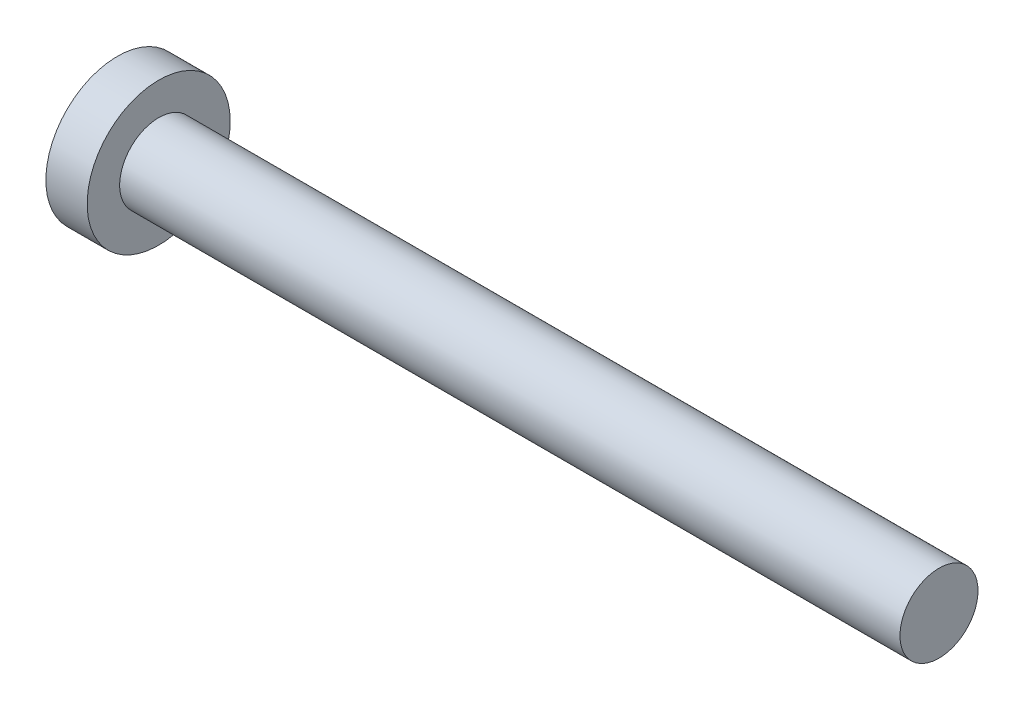
from build123d import *

# Parameters (mm, degrees)
CUT_EXTRUDE2_DEPTH = 1.43
FILLET5_R          = 0.3
DRAFT2_ANGLE       = -30


with BuildPart() as part:
    # Sketch1 → Base (revolve)
    with BuildSketch(Plane.XY):
        with BuildLine():
            Line((32.15, 1.5), (3.15, 1.5))
            Line((3.15, 1.5), (2.15, 1.5))
            Line((2.15, 1.5), (2.15, 1.8))
            Line((2.15, 1.8), (2.15, 2.75))
            Line((2.15, 2.75), (0.562803405, 2.75))
            ThreePointArc((0.562803405, 2.75), (0.142144061, 1.403499882), (0, 0))
            Line((0, 0), (32.15, 0))
            Line((32.15, 0), (32.15, 1.5))
        make_face()
    revolve(axis=Axis((4.515812911, 0, 0), (-1, 0, 0)))

    # Sketch6 → Cut-Extrude2 (cut)
    with BuildSketch(Plane(origin=(0, 0, 0), x_dir=(0, 0, -1), z_dir=(1, 0, 0))):
        Polygon((0.35, 0.35), (0.35, 1.75), (-0.35, 1.75), (-0.35, 0.35), (-1.75, 0.35), (-1.75, -0.35), (-0.35, -0.35), (-0.35, -1.75), (0.35, -1.75), (0.35, -0.35), (1.75, -0.35), (1.75, 0.35), align=None)
    extrude(amount=CUT_EXTRUDE2_DEPTH, mode=Mode.SUBTRACT)

    # Fillet5
    fillet5_edges = [part.edges().sort_by_distance(p)[0] for p in [
        (0.723760965, 0.35, 0.35),
        (0.723760965, -0.35, 0.35),
        (0.723760965, -0.35, -0.35),
        (0.723760965, 0.35, -0.35),
    ]]
    fillet(fillet5_edges, radius=FILLET5_R)

    # Draft2
    draft2_faces = [part.faces().sort_by_distance(p)[0] for p in [
        (0.827643319, 0, 1.75),
        (0.827643319, 1.75, 0),
        (0.827643319, -1.75, 0),
        (0.827643319, 0, -1.75),
    ]]
    draft(draft2_faces, Plane(origin=(0, 0, 0), x_dir=(0, 0, 1), z_dir=(1, 0, 0)), DRAFT2_ANGLE)


solid = part.part
